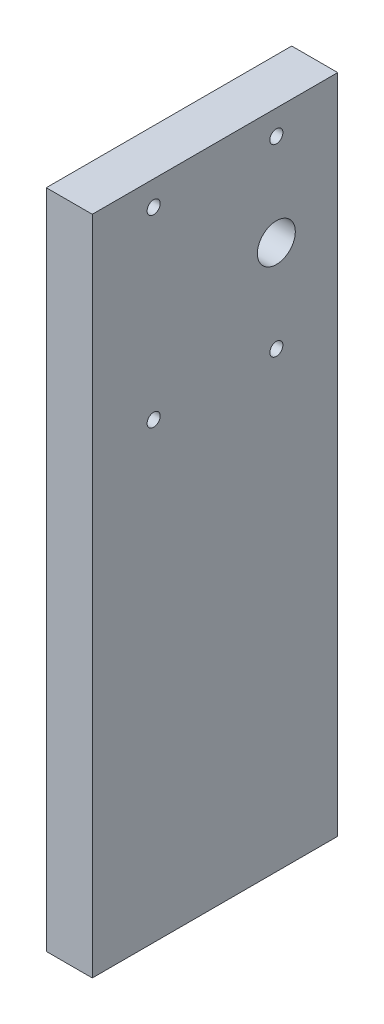
from build123d import *

# Parameters (mm, degrees)
SKETCH1_W             = 50.8
SKETCH1_H             = 136.906
SKETCH1_R             = 3.925
BOSS_EXTRUDE1_DEPTH   = 4.7625
F_6_32_TAPPED_HOLE1_D = 2.7051


with BuildPart() as part:
    # Sketch1 → Boss-Extrude1 (new, symmetric)
    with BuildSketch(Plane(origin=(0, 0, 0), x_dir=(0, 0, -1), z_dir=(1, 0, 0))):
        with Locations((-12.7, -160.147)):
            Rectangle(SKETCH1_W, SKETCH1_H)
        with Locations((0, -115.824)):
            Circle(SKETCH1_R, mode=Mode.SUBTRACT)
    extrude(amount=BOSS_EXTRUDE1_DEPTH, both=True)

    # 6-32 Tapped Hole1 (through all)
    with Locations(Plane(origin=(4.7625, 0, 0), x_dir=(0, 0, -1), z_dir=(1, 0, 0))):
        with Locations((-25.4, -96.774), (0, -96.774), (0, -134.874), (-25.4, -134.874)):
            Hole(F_6_32_TAPPED_HOLE1_D / 2)


solid = part.part
